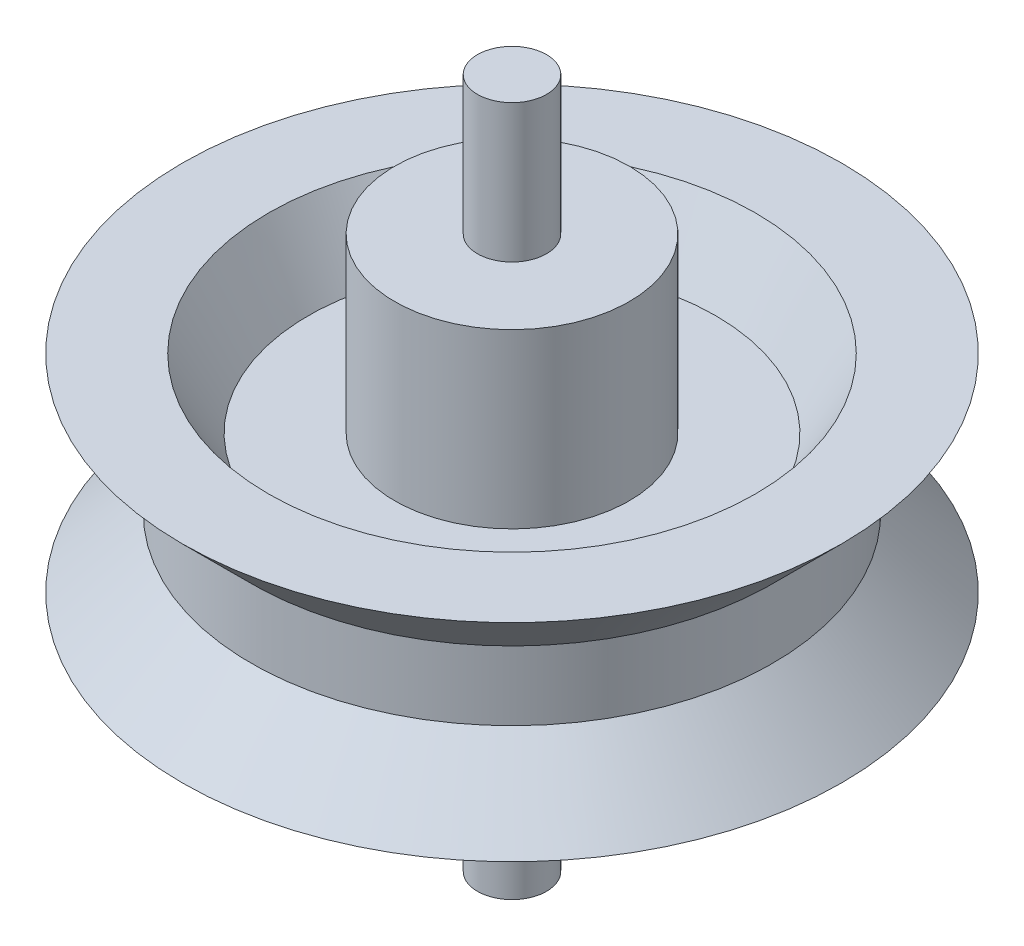
from build123d import *


with BuildPart() as part:
    # Esquisse2 → Révolution1 (revolve)
    with BuildSketch(Plane(origin=(0, 0, 0), x_dir=(0, 0, -1), z_dir=(1, 0, 0))):
        Polygon((3.4, 0), (3.4, -5), (1, -5), (1, -9), (0, -9), (0, 11), (1, 11), (1, 7), (3.4, 7), (3.4, 2), (5.9, 2), (7.054700538, 4), (9.554700538, 4), (7.554700538, 2), (7.554700538, 0), (9.554700538, -2), (7.054700538, -2), (5.9, 0), align=None)
    revolve(axis=Axis((0, 0, 0), (0, 1, 0)))


solid = part.part
